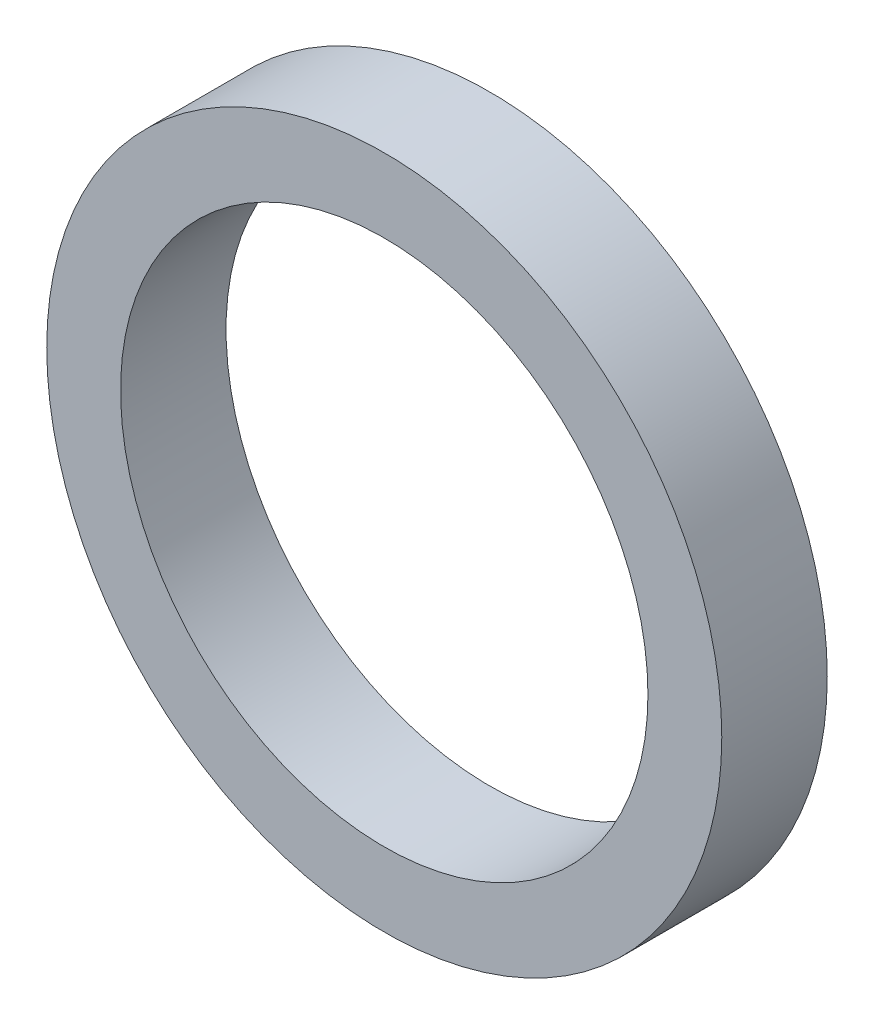
from build123d import *

# Parameters (mm, degrees)
SKETCH1_R           = 32
SKETCH1_R_2         = 25
BOSS_EXTRUDE1_DEPTH = 5


with BuildPart() as part:
    # Sketch1 → Boss-Extrude1 (new body, symmetric)
    with BuildSketch(Plane.XY):
        Circle(SKETCH1_R)
        Circle(SKETCH1_R_2, mode=Mode.SUBTRACT)
    extrude(amount=BOSS_EXTRUDE1_DEPTH, both=True)


solid = part.part
